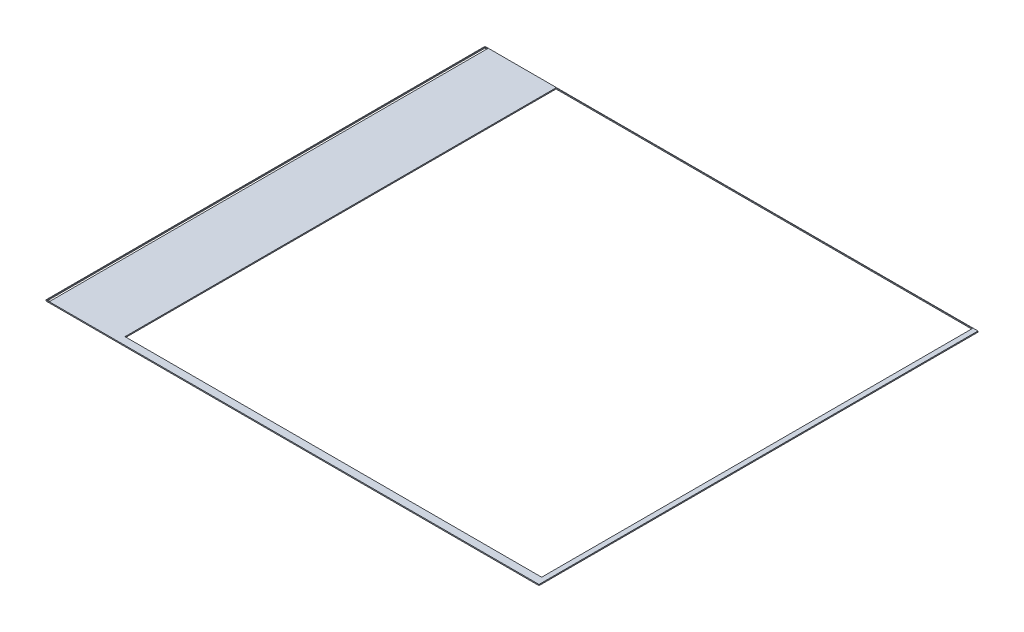
from build123d import *

# Parameters (mm, degrees)
SKETCH1_W          = 22.73
SKETCH1_H          = 20.24
EXTRUDE1_DEPTH     = 0.05
SKETCH2_W          = 0.13
SKETCH2_H          = 20.185
CUT_EXTRUDE1_DEPTH = 1.05
SKETCH3_W          = 19.2096
SKETCH3_H          = 19.872
CUT_EXTRUDE2_DEPTH = 1.05


with BuildPart() as part:
    # Sketch1 → Extrude1 (new body)
    with BuildSketch(Plane(origin=(0, 0, 0), x_dir=(1, 0, 0), z_dir=(0, 1, 0))):
        Rectangle(SKETCH1_W, SKETCH1_H)
    extrude(amount=EXTRUDE1_DEPTH)

    # Sketch2 → Cut-Extrude1 (cut, through all)
    with BuildSketch(Plane.XZ):
        with Locations((-11.2796, -0.00435)):
            Rectangle(SKETCH2_W, SKETCH2_H)
    extrude(amount=-CUT_EXTRUDE1_DEPTH, mode=Mode.SUBTRACT)

    # Sketch3 → Cut-Extrude2 (cut, through all)
    with BuildSketch(Plane.XZ):
        with Locations((1.533, -0.165375)):
            Rectangle(SKETCH3_W, SKETCH3_H)
    extrude(amount=-CUT_EXTRUDE2_DEPTH, mode=Mode.SUBTRACT)


solid = part.part
